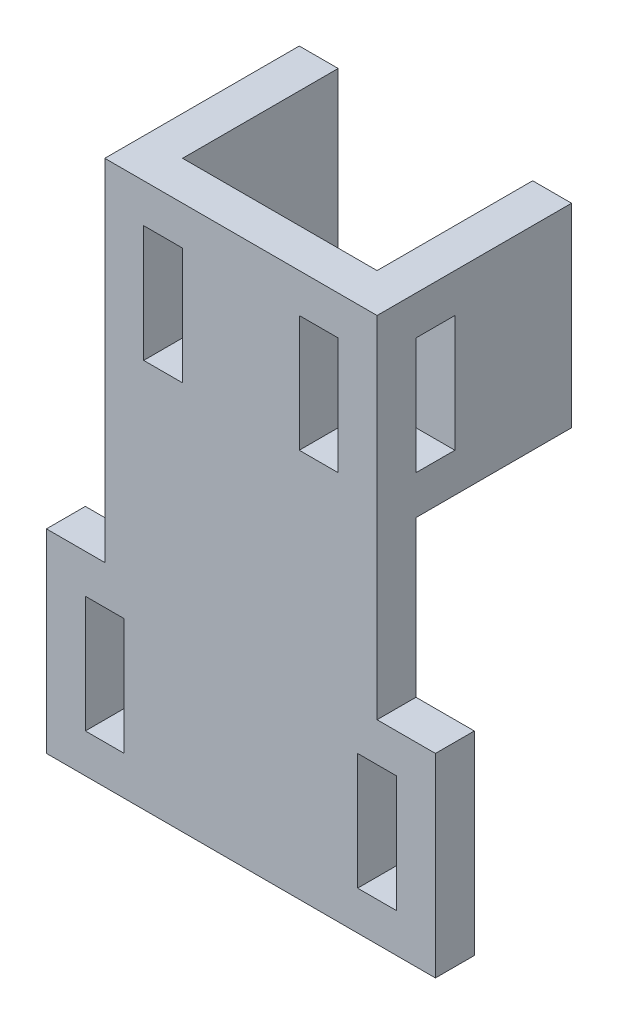
from build123d import *

# Parameters (mm, degrees)
BOSS_EXTRUDE1_DEPTH = 2
SKETCH2_W           = 5
SKETCH2_H           = 25
SKETCH2_W_2         = 20
BOSS_EXTRUDE2_DEPTH = 20
SKETCH3_W           = 25
SKETCH3_H           = 2
BOSS_EXTRUDE3_DEPTH = 25
SKETCH4_W           = 25
SKETCH4_H           = 25
BOSS_EXTRUDE4_DEPTH = 7
BOSS_EXTRUDE5_DEPTH = 5
SKETCH6_W           = 50
SKETCH6_H           = 25
BOSS_EXTRUDE6_DEPTH = 5
BOSS_EXTRUDE7_DEPTH = 30
CUT_EXTRUDE2_DEPTH  = 30
SKETCH10_W          = 5
SKETCH10_H          = 25
CUT_EXTRUDE3_DEPTH  = 20
SKETCH11_W          = 25
SKETCH11_H          = 25
CUT_EXTRUDE4_DEPTH  = 7
SKETCH13_W          = 5
SKETCH13_H          = 25
CUT_EXTRUDE5_DEPTH  = 10
BOSS_EXTRUDE8_REACH = 12
SKETCH14_W          = 10
SKETCH14_H          = 5
SKETCH15_W          = 2.5
SKETCH15_H          = 25
CUT_EXTRUDE6_DEPTH  = 15
SKETCH16_W          = 5
SKETCH16_H          = 15
CUT_EXTRUDE7_DEPTH  = 26
SKETCH17_W          = 5
SKETCH17_H          = 15
CUT_EXTRUDE8_DEPTH  = 43.5
SKETCH18_W          = 5
SKETCH18_H          = 15
CUT_EXTRUDE9_DEPTH  = 6


with BuildPart() as part:
    # Sketch1 → Boss-Extrude1 (new body)
    with BuildSketch(Plane.XY):
        Polygon((-5, 75), (2.5, 25), (2.5, 0), (22.5, 0), (22.5, 25), (30, 75), (30, 100), (25, 100), (25, 75), (0, 75), (0, 100), (-5, 100), align=None)
    extrude(amount=BOSS_EXTRUDE1_DEPTH)

    # Sketch2 → Boss-Extrude2 (add)
    with BuildSketch(Plane(origin=(0, 0, 0), x_dir=(-1, 0, 0), z_dir=(0, 0, -1))):
        with Locations((-27.5, 87.5)):
            Rectangle(SKETCH2_W, SKETCH2_H)
        with Locations((2.5, 87.5)):
            Rectangle(SKETCH2_W, SKETCH2_H)
        with Locations((-12.5, 12.5)):
            Rectangle(SKETCH2_W_2, SKETCH2_H)
    extrude(amount=BOSS_EXTRUDE2_DEPTH)

    # Sketch3 → Boss-Extrude3 (add)
    with BuildSketch(Plane(origin=(0, 75, 0), x_dir=(1, 0, 0), z_dir=(0, 1, 0))):
        with Locations((12.5, -1)):
            Rectangle(SKETCH3_W, SKETCH3_H)
    extrude(amount=BOSS_EXTRUDE3_DEPTH)

    # Sketch4 → Boss-Extrude4 (add)
    with BuildSketch(Plane(origin=(0, 0, 0), x_dir=(-1, 0, 0), z_dir=(0, 0, -1))):
        with Locations((-12.5, 87.5)):
            Rectangle(SKETCH4_W, SKETCH4_H)
    extrude(amount=BOSS_EXTRUDE4_DEPTH)

    # Sketch5 → Boss-Extrude5 (add)
    with BuildSketch(Plane(origin=(0, 0, 0), x_dir=(-1, 0, 0), z_dir=(0, 0, -1))):
        Polygon((5, 75), (5, 0), (-2.5, 0), (-22.5, 0), (-30, 0), (-30, 75), (-30, 100), (5, 100), align=None)
    extrude(amount=-BOSS_EXTRUDE5_DEPTH)

    # Sketch6 → Boss-Extrude6 (add)
    with BuildSketch(Plane.XY.offset(5)):
        with Locations((12.5, 12.5)):
            Rectangle(SKETCH6_W, SKETCH6_H)
    extrude(amount=-BOSS_EXTRUDE6_DEPTH)

    # Sketch8 → Boss-Extrude7 (add)
    with BuildSketch(Plane.XZ.offset(-75)):
        Polygon((-5, 0), (-5, -20), (0, -20), (0, -7), (25, -7), (25, -20), (30, -20), (30, 0), align=None)
    extrude(amount=BOSS_EXTRUDE7_DEPTH)

    # Sketch9 → Cut-Extrude2 (cut)
    with BuildSketch(Plane(origin=(0, 100, 0), x_dir=(1, 0, 0), z_dir=(0, 1, 0))):
        Polygon((30, 20), (25, 20), (25, 7), (0, 7), (0, 20), (-5, 20), (-5, -5), (30, -5), align=None)
    extrude(amount=-CUT_EXTRUDE2_DEPTH, mode=Mode.SUBTRACT)

    # Sketch10 → Cut-Extrude3 (cut)
    with BuildSketch(Plane(origin=(0, 0, -20), x_dir=(-1, 0, 0), z_dir=(0, 0, -1))):
        with Locations((-20, 12.5)):
            Rectangle(SKETCH10_W, SKETCH10_H)
        with Locations((-5, 12.5)):
            Rectangle(SKETCH10_W, SKETCH10_H)
    extrude(amount=-CUT_EXTRUDE3_DEPTH, mode=Mode.SUBTRACT)

    # Sketch11 → Cut-Extrude4 (cut)
    with BuildSketch(Plane(origin=(0, 0, -7), x_dir=(-1, 0, 0), z_dir=(0, 0, -1))):
        with Locations((-12.5, 57.5)):
            Rectangle(SKETCH11_W, SKETCH11_H)
    extrude(amount=-CUT_EXTRUDE4_DEPTH, mode=Mode.SUBTRACT)

    # Sketch13 → Cut-Extrude5 (cut)
    with BuildSketch(Plane(origin=(17.5, 0, 0), x_dir=(0, 0, -1), z_dir=(1, 0, 0))):
        Polygon((5, 25), (5, 20), (10, 20), (10, 5), (0, 5), (0, 25), align=None)
        with Locations((17.5, 12.5)):
            Rectangle(SKETCH13_W, SKETCH13_H)
    extrude(amount=-CUT_EXTRUDE5_DEPTH, mode=Mode.SUBTRACT)

    # Sketch14 → Boss-Extrude8 (add, up to next)
    with BuildSketch(Plane.XY.offset(-5), mode=Mode.PRIVATE) as boss_extrude8_sk1:
        with Locations((12.5, 22.5)):
            Rectangle(SKETCH14_W, SKETCH14_H)
    boss_extrude8_tool1 = extrude(boss_extrude8_sk1.sketch, amount=BOSS_EXTRUDE8_REACH, mode=Mode.PRIVATE) - part.part
    add(boss_extrude8_tool1.solids().sort_by_distance((12.5, 22.5, -5))[0])

    # Sketch15 → Cut-Extrude6 (cut)
    with BuildSketch(Plane(origin=(0, 0, -15), x_dir=(-1, 0, 0), z_dir=(0, 0, -1))):
        with Locations((-8.75, 12.5)):
            Rectangle(SKETCH15_W, SKETCH15_H)
        with Locations((-16.25, 12.5)):
            Rectangle(SKETCH15_W, SKETCH15_H)
    extrude(amount=-CUT_EXTRUDE6_DEPTH, mode=Mode.SUBTRACT)

    # Sketch16 → Cut-Extrude7 (cut, through all)
    with BuildSketch(Plane.XY.offset(5)):
        with Locations((-5, 12.5)):
            Rectangle(SKETCH16_W, SKETCH16_H)
        with Locations((30, 12.5)):
            Rectangle(SKETCH16_W, SKETCH16_H)
    extrude(amount=-CUT_EXTRUDE7_DEPTH, mode=Mode.SUBTRACT)

    # Sketch17 → Cut-Extrude8 (cut, through all)
    with BuildSketch(Plane(origin=(30, 0, 0), x_dir=(0, 0, -1), z_dir=(1, 0, 0))):
        with Locations((2.5, 57.5)):
            Rectangle(SKETCH17_W, SKETCH17_H)
    extrude(amount=-CUT_EXTRUDE8_DEPTH, mode=Mode.SUBTRACT)

    # Sketch18 → Cut-Extrude9 (cut, through all)
    with BuildSketch(Plane(origin=(0, 0, 0), x_dir=(-1, 0, 0), z_dir=(0, 0, -1))):
        with Locations((-2.5, 57.5)):
            Rectangle(SKETCH18_W, SKETCH18_H)
        with Locations((-22.5, 57.5)):
            Rectangle(SKETCH18_W, SKETCH18_H)
    extrude(amount=-CUT_EXTRUDE9_DEPTH, mode=Mode.SUBTRACT)


solid = part.part
